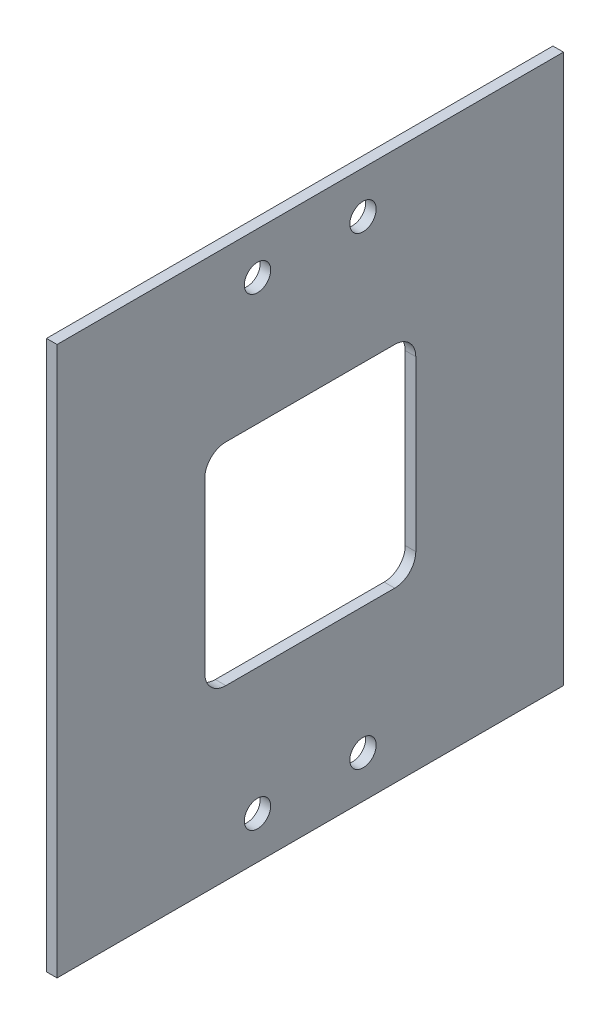
from build123d import *

# Parameters (mm, degrees)
SKETCH1_W           = 152.4
SKETCH1_H           = 165.1
BOSS_EXTRUDE1_DEPTH = 3.175
CUT_EXTRUDE1_DEPTH  = 4.175
SKETCH3_R           = 3.96875
CUT_EXTRUDE2_DEPTH  = 4.175


with BuildPart() as part:
    # Sketch1 → Boss-Extrude1 (new body)
    with BuildSketch(Plane(origin=(0, 0, 0), x_dir=(0, 0, -1), z_dir=(1, 0, 0))):
        with Locations((76.2, 0)):
            Rectangle(SKETCH1_W, SKETCH1_H)
    extrude(amount=BOSS_EXTRUDE1_DEPTH)

    # Sketch2 → Cut-Extrude1 (cut, through all)
    with BuildSketch(Plane.ZY):
        with BuildLine():
            Line((-107.95, 25.4), (-107.95, -25.4))
            ThreePointArc((-107.95, -25.4), (-106.090128061, -29.890128061), (-101.6, -31.75))
            Line((-101.6, -31.75), (-50.8, -31.75))
            ThreePointArc((-50.8, -31.75), (-46.309871939, -29.890128061), (-44.45, -25.4))
            Line((-44.45, -25.4), (-44.45, 25.4))
            ThreePointArc((-44.45, 25.4), (-46.309871939, 29.890128061), (-50.8, 31.75))
            Line((-50.8, 31.75), (-101.6, 31.75))
            ThreePointArc((-101.6, 31.75), (-106.090128061, 29.890128061), (-107.95, 25.4))
        make_face()
    extrude(amount=-CUT_EXTRUDE1_DEPTH, mode=Mode.SUBTRACT)

    # Sketch3 → Cut-Extrude2 (cut, through all)
    with BuildSketch(Plane.ZY):
        with Locations((-60.325, 69.85)):
            Circle(SKETCH3_R)
        with Locations((-92.075, 69.85)):
            Circle(SKETCH3_R)
        with Locations((-92.075, -69.85)):
            Circle(SKETCH3_R)
        with Locations((-60.325, -69.85)):
            Circle(SKETCH3_R)
    extrude(amount=-CUT_EXTRUDE2_DEPTH, mode=Mode.SUBTRACT)


solid = part.part
